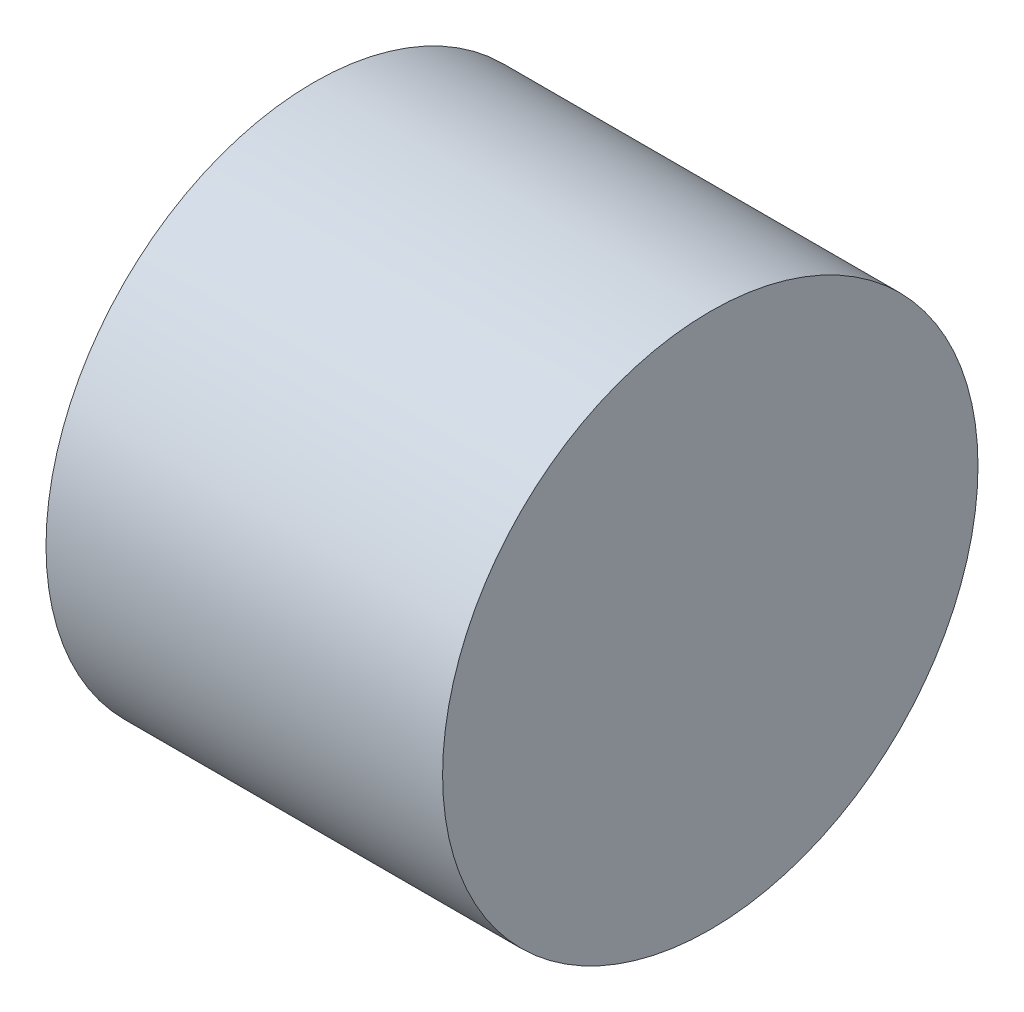
from build123d import *

# Parameters (mm, degrees)
SKETCH1_R           = 13.5
BOSS_EXTRUDE1_DEPTH = 20


with BuildPart() as part:
    # Sketch1 → Boss-Extrude1 (new body)
    with BuildSketch(Plane(origin=(0, 0, 0), x_dir=(0, 0, -1), z_dir=(1, 0, 0))):
        Circle(SKETCH1_R)
    extrude(amount=BOSS_EXTRUDE1_DEPTH)


solid = part.part
